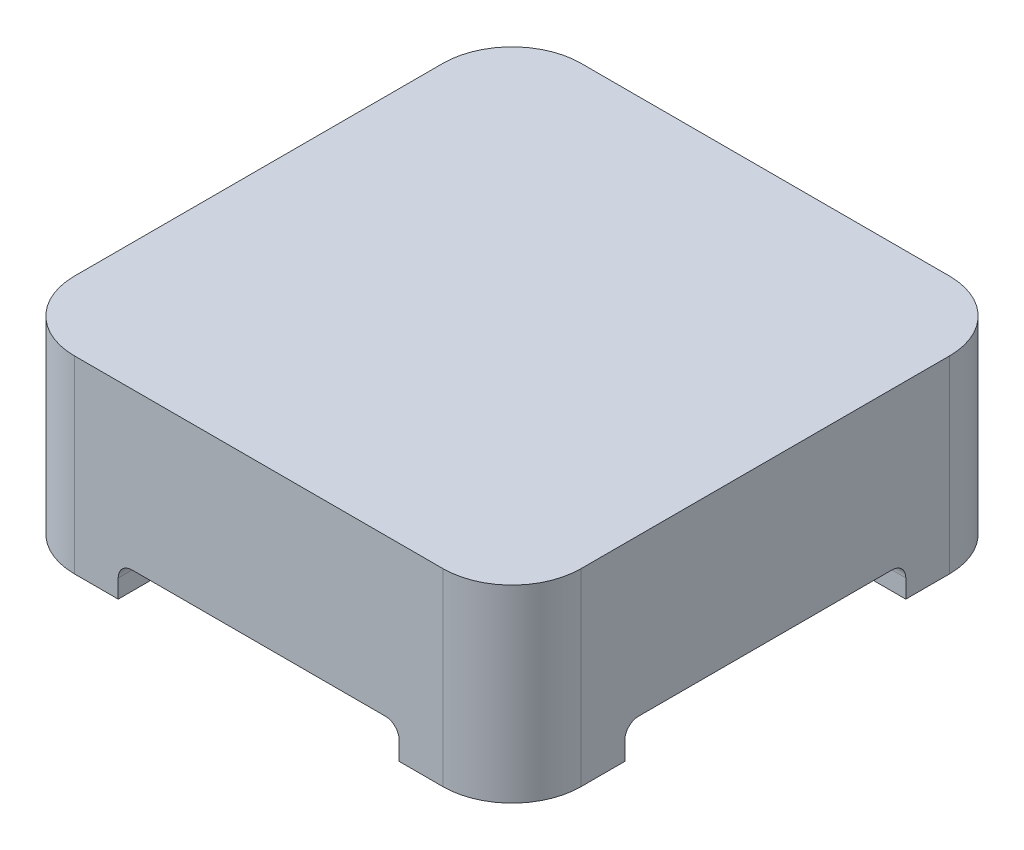
from build123d import *

# Parameters (mm, degrees)
SKIZZE1_W                       = 110
SKIZZE1_H                       = 110
AUFSATZ_LINEAR_AUSTRAGEN1_DEPTH = 41
VERRUNDUNG1_R                   = 15
SCHNITT_LINEAR_AUSTRAGEN1_DEPTH = 111
KREISMUSTER1_COUNT              = 2
KREISMUSTER1_ANGLE              = 90


with BuildPart() as part:
    # Skizze1 → Aufsatz-Linear austragen1 (new body)
    with BuildSketch(Plane(origin=(0, 0, 0), x_dir=(1, 0, 0), z_dir=(0, 1, 0))):
        Rectangle(SKIZZE1_W, SKIZZE1_H)
    extrude(amount=-AUFSATZ_LINEAR_AUSTRAGEN1_DEPTH)

    # Verrundung1
    verrundung1_edges = [part.edges().sort_by_distance(p)[0] for p in [
        (55, -20.5, 55),
        (-55, -20.5, 55),
        (-55, -20.5, -55),
        (55, -20.5, -55),
    ]]
    fillet(verrundung1_edges, radius=VERRUNDUNG1_R)

    # Skizze2 → Schnitt-Linear austragen1 (cut, through all)
    with BuildSketch(Plane.XY.offset(55)):
        with BuildLine():
            Line((-30.5, -41), (-30.5, -37))
            ThreePointArc((-30.5, -37), (-29.621320344, -34.878679656), (-27.5, -34))
            Line((-27.5, -34), (27.5, -34))
            ThreePointArc((27.5, -34), (29.621320344, -34.878679656), (30.5, -37))
            Line((30.5, -37), (30.5, -41))
            Line((30.5, -41), (-30.5, -41))
        make_face()
    schnitt_linear_austragen1 = extrude(amount=-SCHNITT_LINEAR_AUSTRAGEN1_DEPTH, mode=Mode.SUBTRACT)

    # Kreismuster1: Schnitt-Linear austragen1 ×2 about axis
    kreismuster1_axis = Axis((0, -43.05, 0), (0, 1, 0))
    for i in range(1, KREISMUSTER1_COUNT):
        add(schnitt_linear_austragen1.rotate(kreismuster1_axis, i * KREISMUSTER1_ANGLE / (KREISMUSTER1_COUNT - 1)), mode=Mode.SUBTRACT)


solid = part.part
